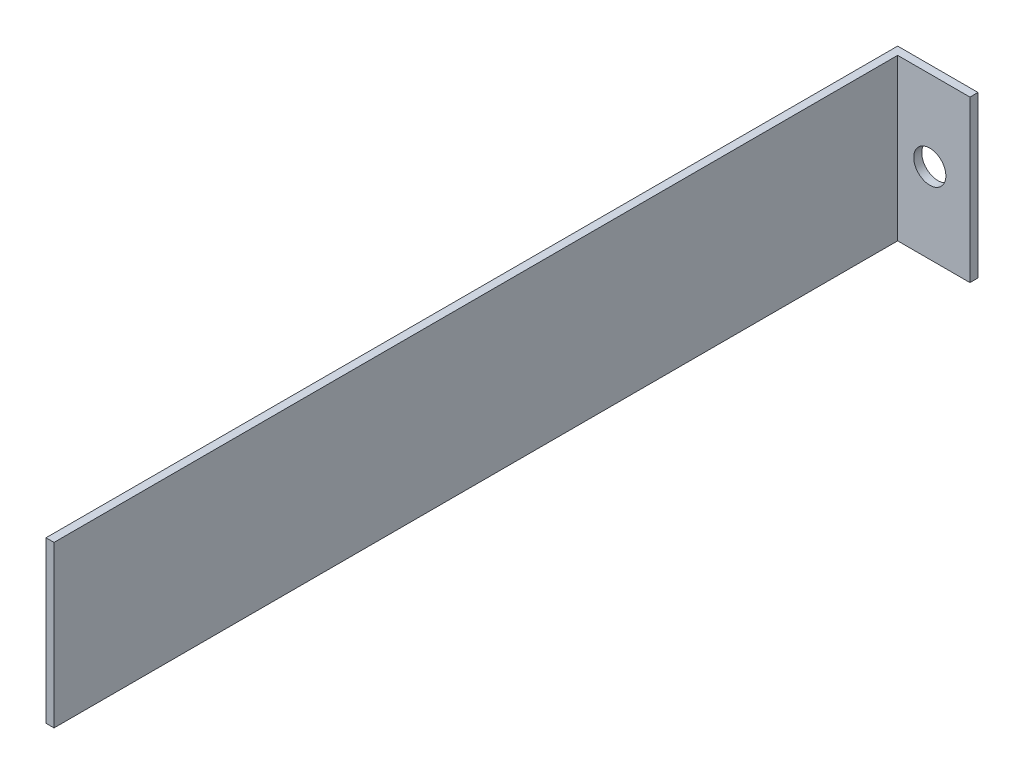
from build123d import *

# Parameters (mm, degrees)
SKETCH_1_W      = 20
SKETCH_1_H      = 40
SKETCH_1_R      = 4
EXTRUDE_1_DEPTH = 2
SKETCH_2_W      = 2
SKETCH_2_H      = 40
EXTRUDE_2_DEPTH = 210


with BuildPart() as part:
    # 草图1 → 凸台-拉伸1 (new body)
    with BuildSketch(Plane.XY):
        with Locations((-27.117483575, 5.837965598)):
            Rectangle(SKETCH_1_W, SKETCH_1_H)
        with Locations((-27.117483575, 5.837965598)):
            Circle(SKETCH_1_R, mode=Mode.SUBTRACT)
    extrude(amount=EXTRUDE_1_DEPTH)

    # 草图2 → 凸台-拉伸2 (add)
    with BuildSketch(Plane.XY.offset(2)):
        with Locations((-36.117483575, 5.837965598)):
            Rectangle(SKETCH_2_W, SKETCH_2_H)
    extrude(amount=EXTRUDE_2_DEPTH)


solid = part.part
